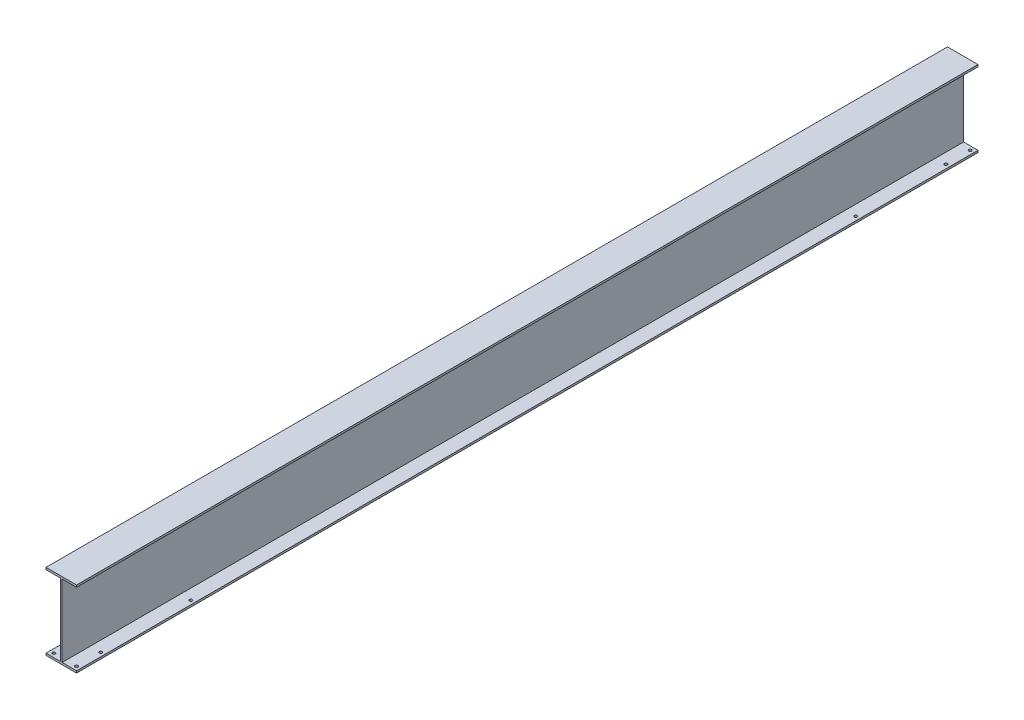
from build123d import *

# Parameters (mm, degrees)
SALIENTE_EXTRUIR1_DEPTH = 3000
CROQUIS2_R              = 4.7625
CORTAR_EXTRUIR1_DEPTH   = 6.8


with BuildPart() as part:
    # Croquis1 → Saliente-Extruir1 (new body)
    with BuildSketch(Plane.XY):
        Polygon((0, 0), (101.6, 0), (101.6, -6.8), (53.7, -6.8), (53.7, -247.2), (101.6, -247.2), (101.6, -254), (0, -254), (0, -247.2), (47.9, -247.2), (47.9, -6.8), (0, -6.8), align=None)
    extrude(amount=SALIENTE_EXTRUIR1_DEPTH)

    # Croquis2 → Cortar-Extruir1 (cut)
    with BuildSketch(Plane.XZ.offset(254)):
        with Locations((88.6, 2987)):
            Circle(CROQUIS2_R)
        with Locations((88.6, 2906.61)):
            Circle(CROQUIS2_R)
        with Locations((13, 2906.61)):
            Circle(CROQUIS2_R)
        with Locations((13, 2987)):
            Circle(CROQUIS2_R)
        with Locations((13, 13)):
            Circle(CROQUIS2_R)
        with Locations((13, 93.39)):
            Circle(CROQUIS2_R)
        with Locations((88.6, 93.39)):
            Circle(CROQUIS2_R)
        with Locations((88.6, 13)):
            Circle(CROQUIS2_R)
        with Locations((88.6, 2606.6)):
            Circle(CROQUIS2_R)
        with Locations((13, 2606.6)):
            Circle(CROQUIS2_R)
        with Locations((13, 393.4)):
            Circle(CROQUIS2_R)
        with Locations((88.6, 393.4)):
            Circle(CROQUIS2_R)
    extrude(amount=-CORTAR_EXTRUIR1_DEPTH, mode=Mode.SUBTRACT)


solid = part.part
